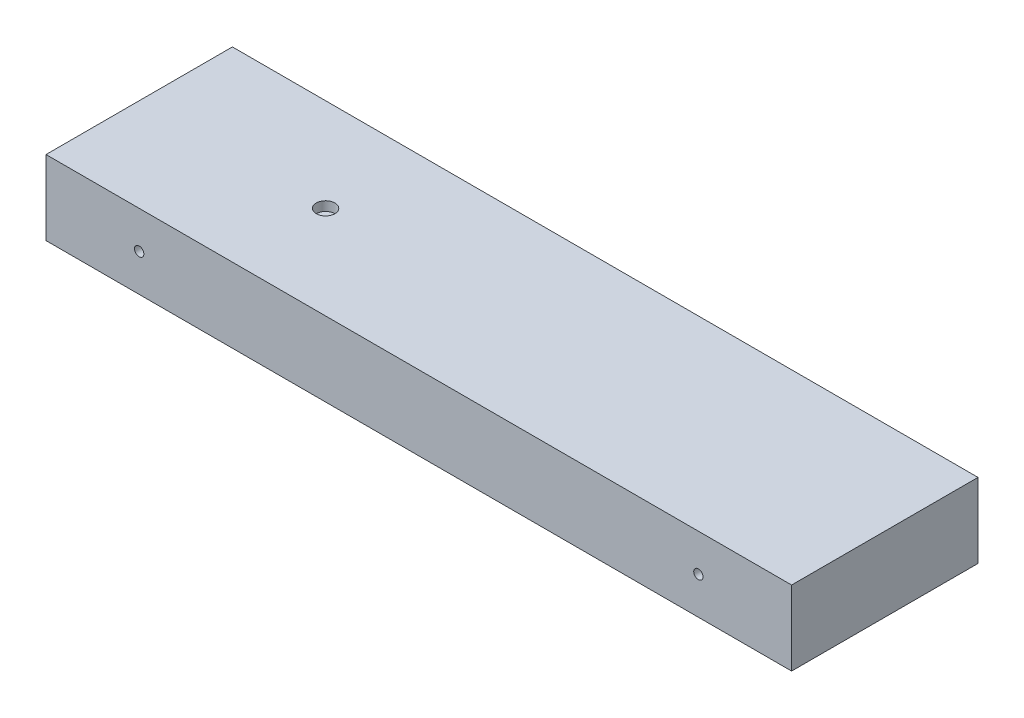
from build123d import *

# Parameters (mm, degrees)
SKETCH1_W           = 800
SKETCH1_H           = 200
BOSS_EXTRUDE1_DEPTH = 80
SKETCH3_R           = 5
CUT_EXTRUDE2_DEPTH  = 200
SKETCH4_R           = 10
CUT_EXTRUDE3_DEPTH  = 10


with BuildPart() as part:
    # Sketch1 → Boss-Extrude1 (new body)
    with BuildSketch(Plane(origin=(0, 0, 0), x_dir=(1, 0, 0), z_dir=(0, 1, 0))):
        with Locations((400, 100)):
            Rectangle(SKETCH1_W, SKETCH1_H)
    extrude(amount=BOSS_EXTRUDE1_DEPTH)

    # Sketch3 → Cut-Extrude2 (cut)
    with BuildSketch(Plane.XY):
        with Locations((100, 40)):
            Circle(SKETCH3_R)
        with Locations((700, 40)):
            Circle(SKETCH3_R)
    extrude(amount=-CUT_EXTRUDE2_DEPTH, mode=Mode.SUBTRACT)

    # Sketch4 → Cut-Extrude3 (cut)
    with BuildSketch(Plane(origin=(0, 80, 0), x_dir=(1, 0, 0), z_dir=(0, 1, 0))):
        with Locations((200, 100)):
            Circle(SKETCH4_R)
    extrude(amount=-CUT_EXTRUDE3_DEPTH, mode=Mode.SUBTRACT)


solid = part.part
